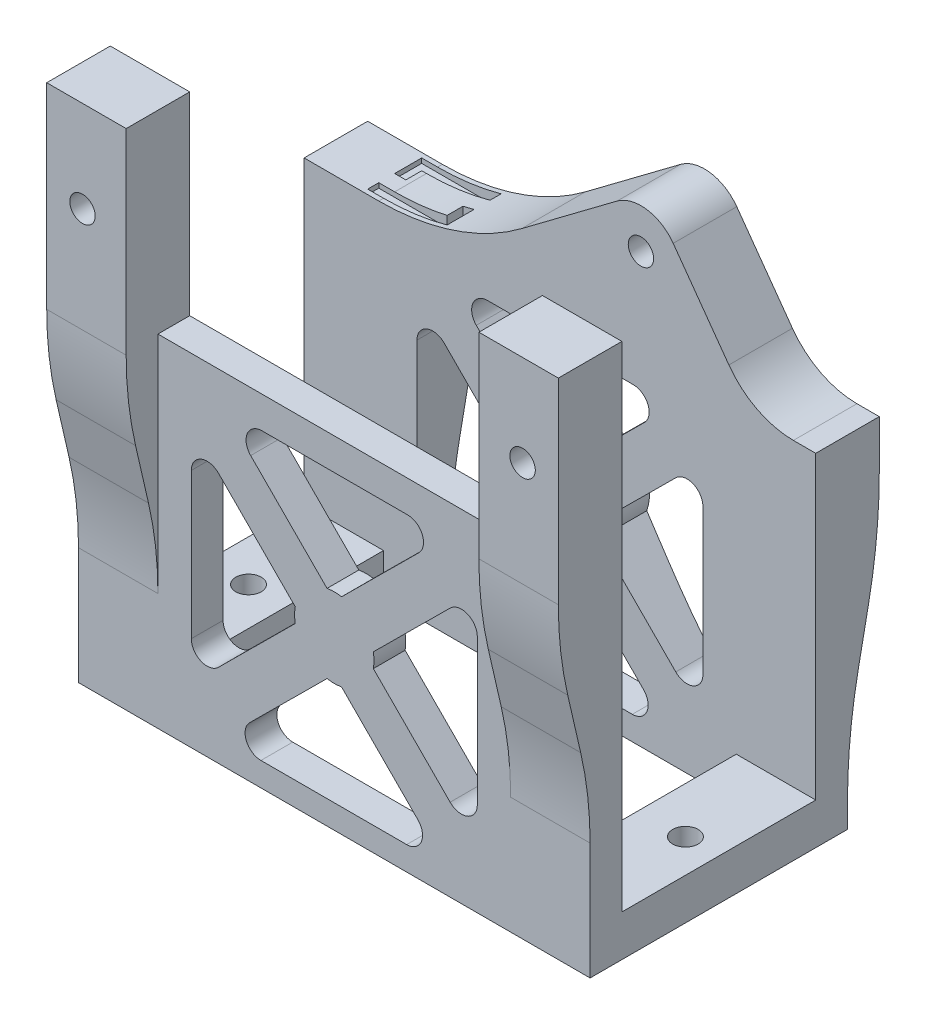
from build123d import *

# Parameters (mm, degrees)
CROQUIS1_W                        = 5
CROQUIS1_H                        = 16.2
SALIENTE_EXTRUIR1_DEPTH           = 3
SALIENTE_EXTRUIR1_2_DEPTH         = 3
CROQUIS2_R                        = 0.8
CORTAR_EXTRUIR2_DEPTH             = 3
CROQUIS4_W                        = 32.2
CROQUIS4_H                        = 2
SALIENTE_EXTRUIR2_DEPTH           = 18.5
SALIENTE_EXTRUIR2_DEPTH_BACK      = 3
CROQUIS5_W                        = 5
CROQUIS5_H                        = 12.2
SALIENTE_EXTRUIR3_DEPTH           = 2
SALIENTE_EXTRUIR4_DEPTH           = 32.2
CORTAR_EXTRUIR3_REACH             = 35.7
CROQUIS8_W                        = 22.2
CROQUIS8_H                        = 2
CORTAR_EXTRUIR3_DIRECTION_2_DEPTH = 1
CORTAR_EXTRUIR4_REACH             = 20.2
CROQUIS9_R                        = 0.8
CROQUIS10_R                       = 0.8
SALIENTE_EXTRUIR5_DEPTH           = 2
SALIENTE_EXTRUIR7_DEPTH           = 32.2
CORTAR_EXTRUIR5_DEPTH             = 19.2
CORTAR_EXTRUIR9_DEPTH             = 0.3
CORTAR_EXTRUIR9_DIRECTION_2_REACH = 14.2
CROQUIS21_W                       = 32.2
CROQUIS21_H                       = 12.2
CORTAR_EXTRUIR10_DEPTH            = 0.4


with BuildPart() as part:
    # Croquis1 → Saliente-Extruir1 (new body)
    with BuildSketch(Plane(origin=(0, 0, 0), x_dir=(1, 0, 0), z_dir=(0, 1, 0))):
        with Locations((-13.6, 0)):
            Rectangle(CROQUIS1_W, CROQUIS1_H)
    extrude(amount=SALIENTE_EXTRUIR1_DEPTH)


with BuildPart() as body_2:
    # Croquis1 → Saliente-Extruir1 2 (new body)
    with BuildSketch(Plane(origin=(0, 0, 0), x_dir=(1, 0, 0), z_dir=(0, 1, 0))):
        with Locations((13.6, 0)):
            Rectangle(CROQUIS1_W, CROQUIS1_H)
    extrude(amount=SALIENTE_EXTRUIR1_2_DEPTH)


with BuildPart() as cortar_extruir2_tool:
    # Croquis2 → Cortar-Extruir2 (new body)
    with BuildSketch(Plane(origin=(0, 3, 0), x_dir=(1, 0, 0), z_dir=(0, 1, 0))):
        with Locations((-13.5, 0)):
            Circle(CROQUIS2_R)
        with Locations((14, 0)):
            Circle(CROQUIS2_R)
    extrude(amount=-CORTAR_EXTRUIR2_DEPTH)


with BuildPart() as part_1:
    add(part.part)

    # Cortar-Extruir2: cut by cortar_extruir2_tool
    add(cortar_extruir2_tool.part, mode=Mode.SUBTRACT)



with BuildPart() as body_2_1:
    add(body_2.part)

    # Cortar-Extruir2: cut by cortar_extruir2_tool
    add(cortar_extruir2_tool.part, mode=Mode.SUBTRACT)


with BuildPart() as part_2:
    add(part_1.part)

    add(body_2_1.part)  # Saliente-Extruir2 merges body 2
    # Croquis4 → Saliente-Extruir2 (add, two sides)
    with BuildSketch(Plane(origin=(0, 3, 0), x_dir=(1, 0, 0), z_dir=(0, 1, 0))) as saliente_extruir2_sk:
        with Locations((0, 7.1)):
            Rectangle(CROQUIS4_W, CROQUIS4_H)
        with Locations((0, -7.1)):
            Rectangle(CROQUIS4_W, CROQUIS4_H)
    extrude(amount=SALIENTE_EXTRUIR2_DEPTH)
    extrude(saliente_extruir2_sk.sketch, amount=-SALIENTE_EXTRUIR2_DEPTH_BACK)

    # Croquis5 → Saliente-Extruir3 (add)
    with BuildSketch(Plane.XY.offset(8.1)):
        with Locations((13.6, 27.6)):
            Rectangle(CROQUIS5_W, CROQUIS5_H)
        with Locations((-13.6, 27.6)):
            Rectangle(CROQUIS5_W, CROQUIS5_H)
    extrude(amount=-SALIENTE_EXTRUIR3_DEPTH)

    # Croquis7 → Saliente-Extruir4 (add, through all)
    with BuildSketch(Plane.ZY.offset(16.1)):
        with BuildLine():
            Line((10.1, 33.7), (8.1, 33.7))
            Line((8.1, 33.7), (8.1, 7.353005636))
            ThreePointArc((8.1, 7.353005636), (8.248733131, 9.983124325), (8.693036056, 12.579706844))
            Line((8.693036056, 12.579706844), (9.506963944, 16.120293156))
            ThreePointArc((9.506963944, 16.120293156), (9.951266869, 18.716875675), (10.1, 21.346994364))
            Line((10.1, 21.346994364), (10.1, 33.7))
        make_face()
    extrude(amount=-SALIENTE_EXTRUIR4_DEPTH)

    # Croquis8 → Cortar-Extruir3 (cut, up to next)
    with BuildSketch(Plane(origin=(0, 33.7, 0), x_dir=(1, 0, 0), z_dir=(0, 1, 0)), mode=Mode.PRIVATE) as cortar_extruir3_sk1:
        with Locations((0, -9.1)):
            Rectangle(CROQUIS8_W, CROQUIS8_H)
    cortar_extruir3_tool1 = extrude(cortar_extruir3_sk1.sketch, amount=-CORTAR_EXTRUIR3_REACH, mode=Mode.PRIVATE) & part_2.part
    add(cortar_extruir3_tool1.solids().sort_by_distance((0, 33.7, 9.1))[0], mode=Mode.SUBTRACT)

    # Croquis8 → Cortar-Extruir3 direction 2 (cut)
    with BuildSketch(Plane(origin=(0, 33.7, 0), x_dir=(1, 0, 0), z_dir=(0, 1, 0))):
        with Locations((0, -9.1)):
            Rectangle(CROQUIS8_W, CROQUIS8_H)
    extrude(amount=CORTAR_EXTRUIR3_DIRECTION_2_DEPTH, mode=Mode.SUBTRACT)

    # Croquis9 → Cortar-Extruir4 (cut, up to next)
    with BuildSketch(Plane.XY.offset(10.1), mode=Mode.PRIVATE) as cortar_extruir4_sk1:
        with Locations((-13.85, 27.95)):
            Circle(CROQUIS9_R)
    cortar_extruir4_tool1 = extrude(cortar_extruir4_sk1.sketch, amount=-CORTAR_EXTRUIR4_REACH, mode=Mode.PRIVATE) & part_2.part
    add(cortar_extruir4_tool1.solids().sort_by_distance((-13.85, 27.95, 10.1))[0], mode=Mode.SUBTRACT)
    # Croquis9 → Cortar-Extruir4 (cut, up to next)
    with BuildSketch(Plane.XY.offset(10.1), mode=Mode.PRIVATE) as cortar_extruir4_sk2:
        with Locations((13.85, 27.95)):
            Circle(CROQUIS9_R)
    cortar_extruir4_tool2 = extrude(cortar_extruir4_sk2.sketch, amount=-CORTAR_EXTRUIR4_REACH, mode=Mode.PRIVATE) & part_2.part
    add(cortar_extruir4_tool2.solids().sort_by_distance((13.85, 27.95, 10.1))[0], mode=Mode.SUBTRACT)

    # Croquis10 → Saliente-Extruir5 (add, symmetric)
    with BuildSketch(Plane(origin=(0, 0, -8.1), x_dir=(-1, 0, 0), z_dir=(0, 0, -1))):
        with BuildLine():
            Line((-10.633991508, 23.582443769), (-7.130262645, 28.458778116))
            ThreePointArc((-7.130262645, 28.458778116), (-5.478846803, 29.471128305), (-3.6, 29))
            Line((-3.6, 29), (2.4, 24.5))
            ThreePointArc((2.4, 24.5), (6.65658351, 22.269750529), (11.4, 21.5))
            Line((11.4, 21.5), (-14.694516799, 21.5))
            ThreePointArc((-14.694516799, 21.5), (-12.412826763, 22.050967456), (-10.633991508, 23.582443769))
        make_face()
        with Locations((-5.1, 27)):
            Circle(CROQUIS10_R, mode=Mode.SUBTRACT)
    extrude(amount=SALIENTE_EXTRUIR5_DEPTH, both=True)

    # Croquis13 → Saliente-Extruir7 (add, through all)
    with BuildSketch(Plane.ZY.offset(16.1)):
        with BuildLine():
            Line((-8.1, 21.5), (-10.1, 21.5))
            Line((-10.1, 21.5), (-10.1, 18.465682976))
            ThreePointArc((-10.1, 18.465682976), (-9.929666433, 15.016866347), (-9.420323649, 11.601618246))
            Line((-9.420323649, 11.601618246), (-8.779676351, 8.398381754))
            ThreePointArc((-8.779676351, 8.398381754), (-8.270333567, 4.983133653), (-8.1, 1.534317024))
            Line((-8.1, 1.534317024), (-8.1, 21.5))
        make_face()
    extrude(amount=-SALIENTE_EXTRUIR7_DEPTH)

    # Croquis14 → Cortar-Extruir5 (cut, through all)
    with BuildSketch(Plane.XY.offset(8.1)):
        with BuildLine():
            Line((-9, 15.116941663), (-9, 5.945455337))
            ThreePointArc((-9, 5.945455337), (-8.38417979, 5.022197037), (-7.295188221, 5.236060978))
            Line((-7.295188221, 5.236060978), (-2.457737974, 10.042262026))
            ThreePointArc((-2.457737974, 10.042262026), (-2.499999997, 10.499882305), (-2.457781062, 10.95750656))
            Line((-2.457781062, 10.95750656), (-7.290605641, 15.821753441))
            ThreePointArc((-7.290605641, 15.821753441), (-8.381186071, 16.041440002), (-9, 15.116941663))
        make_face()
        with BuildLine():
            Line((-5.263939022, 17.795188221), (-0.457737974, 12.957737974))
            ThreePointArc((-0.457737974, 12.957737974), (-0.000117695, 12.999999997), (0.45750656, 12.957781062))
            Line((0.45750656, 12.957781062), (5.321753441, 17.790605641))
            ThreePointArc((5.321753441, 17.790605641), (5.541440002, 18.881186071), (4.616941663, 19.5))
            Line((4.616941663, 19.5), (-4.554544663, 19.5))
            ThreePointArc((-4.554544663, 19.5), (-5.477802963, 18.88417979), (-5.263939022, 17.795188221))
        make_face()
        with BuildLine():
            Line((7.295188221, 15.763939022), (2.457737974, 10.957737974))
            ThreePointArc((2.457737974, 10.957737974), (2.499999997, 10.500117695), (2.457781062, 10.04249344))
            Line((2.457781062, 10.04249344), (7.290605641, 5.178246559))
            ThreePointArc((7.290605641, 5.178246559), (8.381186071, 4.958559998), (9, 5.883058337))
            Line((9, 5.883058337), (9, 15.054544663))
            ThreePointArc((9, 15.054544663), (8.38417979, 15.977802963), (7.295188221, 15.763939022))
        make_face()
        with BuildLine():
            Line((5.263939022, 3.204811779), (0.457737974, 8.042262026))
            ThreePointArc((0.457737974, 8.042262026), (0.000117695, 8.000000003), (-0.45750656, 8.042218938))
            Line((-0.45750656, 8.042218938), (-5.321753441, 3.209394359))
            ThreePointArc((-5.321753441, 3.209394359), (-5.541440002, 2.118813929), (-4.616941663, 1.5))
            Line((-4.616941663, 1.5), (4.554544663, 1.5))
            ThreePointArc((4.554544663, 1.5), (5.477802963, 2.11582021), (5.263939022, 3.204811779))
        make_face()
    extrude(amount=-CORTAR_EXTRUIR5_DEPTH, mode=Mode.SUBTRACT)

    # Croquis20 → Cortar-Extruir9 (cut)
    with BuildSketch(Plane(origin=(0, 21.5, 0), x_dir=(1, 0, 0), z_dir=(0, 1, 0))):
        Polygon((-12.4, 6.4), (-7.4, 6.4), (-7.4, 8.1), (-8.1, 8.1), (-8.1, 7.1), (-12.4, 7.1), align=None)
        Polygon((-7.4, 9.1), (-7.4, 9.8), (-12.4, 9.8), (-12.4, 8.1), (-11.7, 8.1), (-11.7, 9.1), align=None)
    extrude(amount=-CORTAR_EXTRUIR9_DEPTH, mode=Mode.SUBTRACT)

    # Croquis20 → Cortar-Extruir9 direction 2 (cut, up to next)
    with BuildSketch(Plane(origin=(0, 21.5, 0), x_dir=(1, 0, 0), z_dir=(0, 1, 0)), mode=Mode.PRIVATE) as cortar_extruir9_direction_2_sk1:
        Polygon((-12.4, 6.4), (-7.4, 6.4), (-7.4, 8.1), (-8.1, 8.1), (-8.1, 7.1), (-12.4, 7.1), align=None)
    cortar_extruir9_direction_2_tool1 = extrude(cortar_extruir9_direction_2_sk1.sketch, amount=CORTAR_EXTRUIR9_DIRECTION_2_REACH, mode=Mode.PRIVATE) & part_2.part
    add(cortar_extruir9_direction_2_tool1.solids().sort_by_distance((-9.541667, 21.5, -6.891667))[0], mode=Mode.SUBTRACT)
    # Croquis20 → Cortar-Extruir9 direction 2 (cut, up to next)
    with BuildSketch(Plane(origin=(0, 21.5, 0), x_dir=(1, 0, 0), z_dir=(0, 1, 0)), mode=Mode.PRIVATE) as cortar_extruir9_direction_2_sk2:
        Polygon((-7.4, 9.1), (-7.4, 9.8), (-12.4, 9.8), (-12.4, 8.1), (-11.7, 8.1), (-11.7, 9.1), align=None)
    cortar_extruir9_direction_2_tool2 = extrude(cortar_extruir9_direction_2_sk2.sketch, amount=CORTAR_EXTRUIR9_DIRECTION_2_REACH, mode=Mode.PRIVATE) & part_2.part
    add(cortar_extruir9_direction_2_tool2.solids().sort_by_distance((-10.258333, 21.5, -9.308333))[0], mode=Mode.SUBTRACT)

    # Croquis21 → Cortar-Extruir10 (cut)
    with BuildSketch(Plane(origin=(0, 3, 0), x_dir=(1, 0, 0), z_dir=(0, 1, 0))):
        Rectangle(CROQUIS21_W, CROQUIS21_H)
    extrude(amount=-CORTAR_EXTRUIR10_DEPTH, mode=Mode.SUBTRACT)


solid = part_2.part
